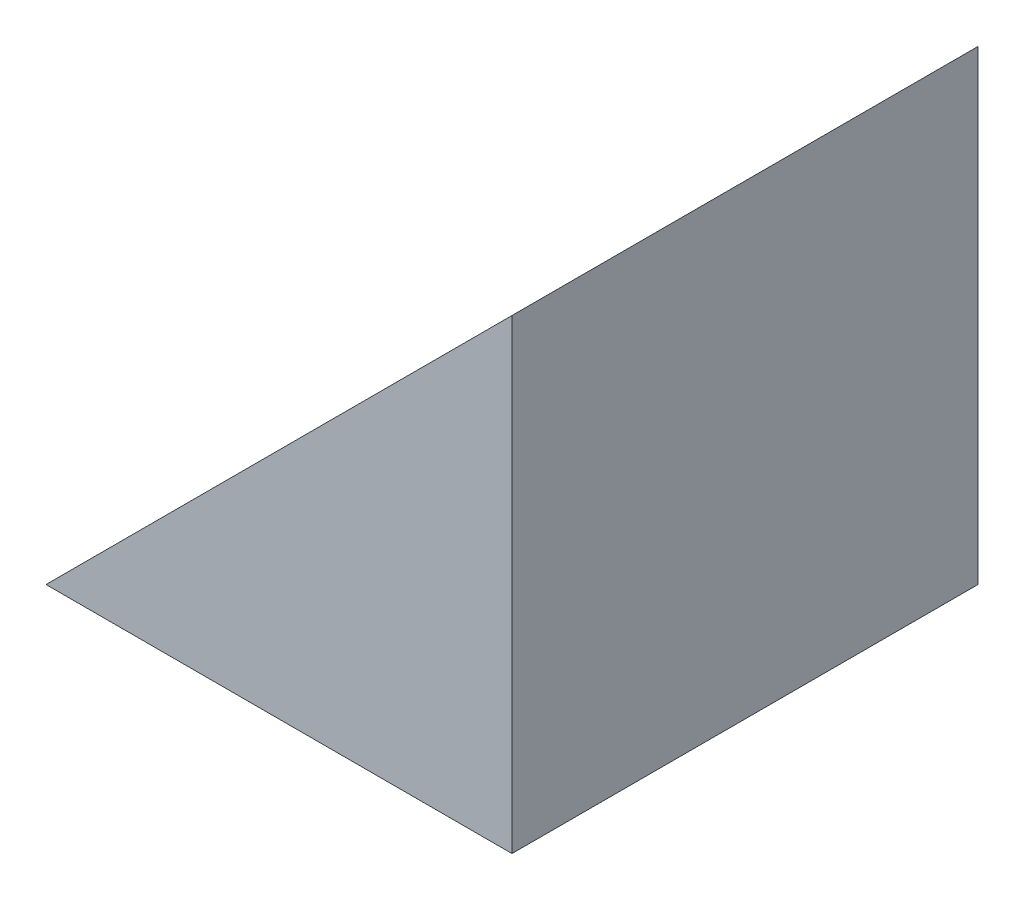
from build123d import *

# Parameters (mm, degrees)
EXTRUDE_1_DEPTH = 5


with BuildPart() as part:
    # 草图1 → 凸台-拉伸1 (new body)
    with BuildSketch(Plane.XY):
        Polygon((17.471406371, 13.277907024), (17.471406371, 18.277907024), (12.471406371, 13.277907024), align=None)
    extrude(amount=EXTRUDE_1_DEPTH)


solid = part.part
